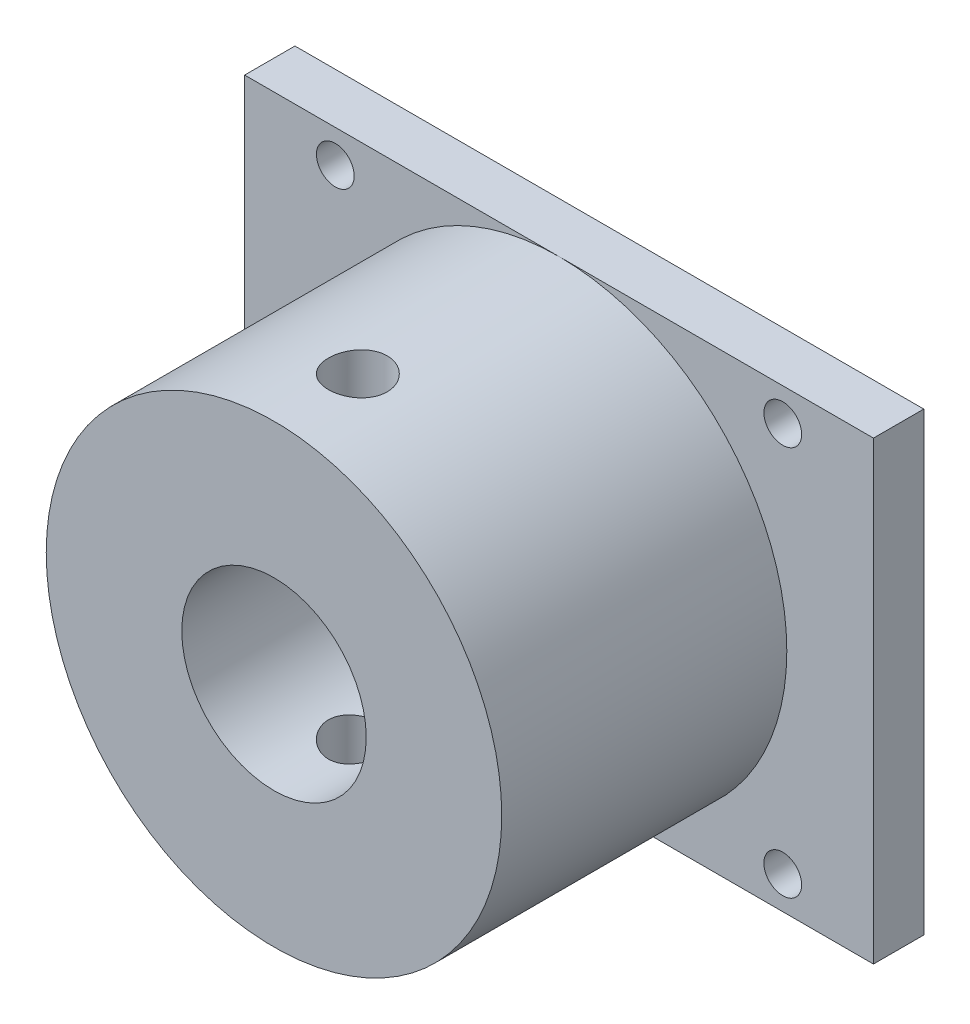
from build123d import *

# Parameters (mm, degrees)
SKETCH1_W                      = 75
SKETCH1_H                      = 54.33
BOSS_EXTRUDE1_DEPTH            = 45
CBORE_FOR_M4_SHCS1_D           = 4.5
CBORE_FOR_M4_SHCS1_CBORE_D     = 8
CBORE_FOR_M4_SHCS1_CBORE_DEPTH = 4
SKETCH4_OUTSIDE_W              = 97.592
SKETCH4_OUTSIDE_H              = 67.592
SKETCH4_OUTSIDE_W_2            = 75
SKETCH4_OUTSIDE_H_2            = 40
CUT_EXTRUDE1_DEPTH             = 80.893672465
SKETCH5_R                      = 8.5
CUT_EXTRUDE2_DEPTH             = 30
SKETCH5_3_R                    = 9
CUT_EXTRUDE3_DEPTH             = 20
SKETCH5_4_R                    = 11
CUT_EXTRUDE4_DEPTH             = 17
SKETCH6_R                      = 3.5
CUT_EXTRUDE5_DEPTH             = 78.188074856
SKETCH29_OUTSIDE_W             = 97.176
SKETCH29_OUTSIDE_H             = 76.506
SKETCH29_OUTSIDE_R             = 27.165
CUT_EXTRUDE6_DEPTH             = 34
SKETCH30_R                     = 4.5
CUT_EXTRUDE7_DEPTH             = 5


with BuildPart() as part:
    # Sketch1 → Boss-Extrude1 (new body)
    with BuildSketch(Plane.XY):
        Rectangle(SKETCH1_W, SKETCH1_H)
    extrude(amount=BOSS_EXTRUDE1_DEPTH)

    # CBORE for M4 SHCS1 (through all)
    with Locations(Plane.XY.offset(45)):
        with Locations((26.685, -23.265), (26.685, 23.265), (-26.685, 23.265), (-26.685, -23.265)):
            CounterBoreHole(CBORE_FOR_M4_SHCS1_D / 2, CBORE_FOR_M4_SHCS1_CBORE_D / 2, CBORE_FOR_M4_SHCS1_CBORE_DEPTH)

    # Sketch4 outside → Cut-Extrude1 (cut, through all)
    with BuildSketch(Plane.XZ.offset(27.165)):
        with Locations((0, 22.5)):
            Rectangle(SKETCH4_OUTSIDE_W, SKETCH4_OUTSIDE_H)
        with Locations((0, 20)):
            Rectangle(SKETCH4_OUTSIDE_W_2, SKETCH4_OUTSIDE_H_2, mode=Mode.SUBTRACT)
    extrude(amount=-CUT_EXTRUDE1_DEPTH, mode=Mode.SUBTRACT)

    # Sketch5 → Cut-Extrude2 (cut)
    with BuildSketch(Plane.XY.offset(40)):
        Circle(SKETCH5_R)
    extrude(amount=-CUT_EXTRUDE2_DEPTH, mode=Mode.SUBTRACT)

    # Sketch5_3 → Cut-Extrude3 (cut)
    with BuildSketch(Plane.XY.offset(40)):
        Circle(SKETCH5_3_R)
    extrude(amount=-CUT_EXTRUDE3_DEPTH, mode=Mode.SUBTRACT)

    # Sketch5_4 → Cut-Extrude4 (cut)
    with BuildSketch(Plane.XY.offset(40)):
        Circle(SKETCH5_4_R)
    extrude(amount=-CUT_EXTRUDE4_DEPTH, mode=Mode.SUBTRACT)

    # Sketch6 → Cut-Extrude5 (cut, through all)
    with BuildSketch(Plane(origin=(0, 27.165, 0), x_dir=(1, 0, 0), z_dir=(0, 1, 0))):
        with Locations((0, -30)):
            Circle(SKETCH6_R)
    extrude(amount=-CUT_EXTRUDE5_DEPTH, mode=Mode.SUBTRACT)

    # Sketch29 outside → Cut-Extrude6 (cut)
    with BuildSketch(Plane.XY.offset(40)):
        Rectangle(SKETCH29_OUTSIDE_W, SKETCH29_OUTSIDE_H)
        Circle(SKETCH29_OUTSIDE_R, mode=Mode.SUBTRACT)
    extrude(amount=-CUT_EXTRUDE6_DEPTH, mode=Mode.SUBTRACT)

    # Sketch30 → Cut-Extrude7 (cut)
    with BuildSketch(Plane(origin=(0, 0, 0), x_dir=(-1, 0, 0), z_dir=(0, 0, -1))):
        with Locations((-13.555, 11.3)):
            Circle(SKETCH30_R)
        with Locations((13.555, 11.3)):
            Circle(SKETCH30_R)
        with Locations((13.555, -11.3)):
            Circle(SKETCH30_R)
        with Locations((-13.555, -11.3)):
            Circle(SKETCH30_R)
    extrude(amount=-CUT_EXTRUDE7_DEPTH, mode=Mode.SUBTRACT)


solid = part.part
